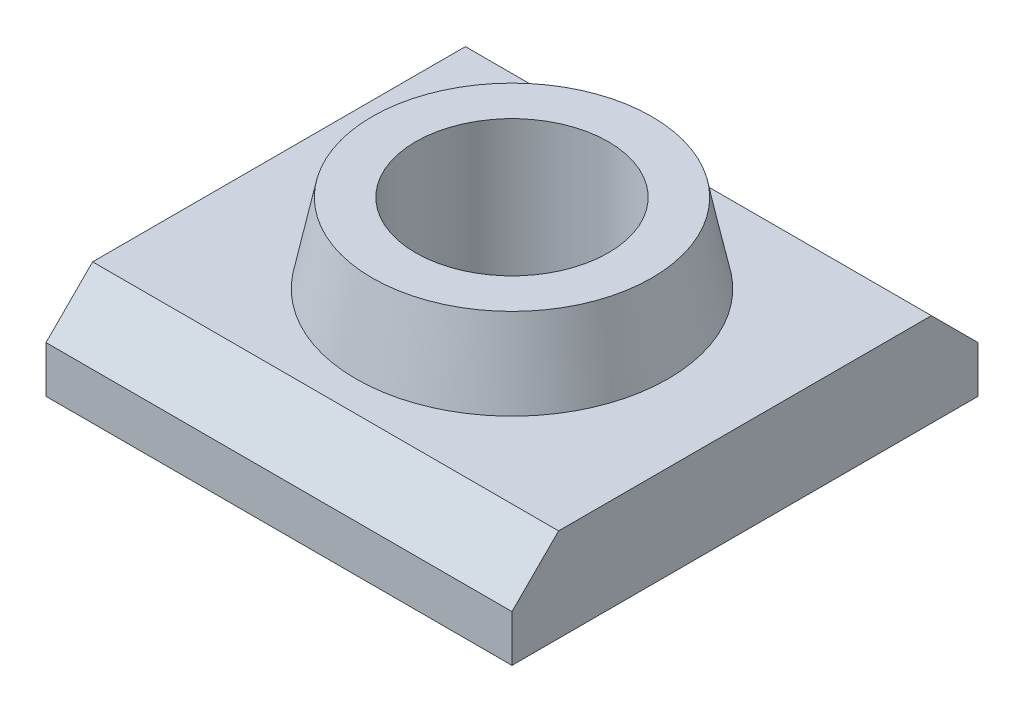
from build123d import *

# Parameters (mm, degrees)
BOSS_EXTRUDE1_DEPTH = 10
TAPPED_HOLE1_D      = 4.134


with BuildPart() as part:
    # Sketch1 → Boss-Extrude1 (new body)
    with BuildSketch(Plane(origin=(-5, 0, 0), x_dir=(0, 0, -1), z_dir=(1, 0, 0))):
        Polygon((4, -1.7), (-4, -1.7), (-5, -2.7), (-5, -3.7), (5, -3.7), (5, -2.7), align=None)
    extrude(amount=BOSS_EXTRUDE1_DEPTH)

    # Sketch2 → Revolve1 (revolve)
    with BuildSketch(Plane(origin=(0, 0, 0), x_dir=(0, 0, -1), z_dir=(1, 0, 0))):
        Polygon((3.35, -1.7), (3, 0), (0, 0), (0, -1.7), align=None)
    revolve(axis=Axis((0, 0, 0), (0, -1, 0)))

    # Tapped Hole1 (through all)
    with Locations(Plane(origin=(0, 0, 0), x_dir=(1, 0, 0), z_dir=(0, 1, 0))):
        with Locations((0, 0)):
            Hole(TAPPED_HOLE1_D / 2)


solid = part.part
